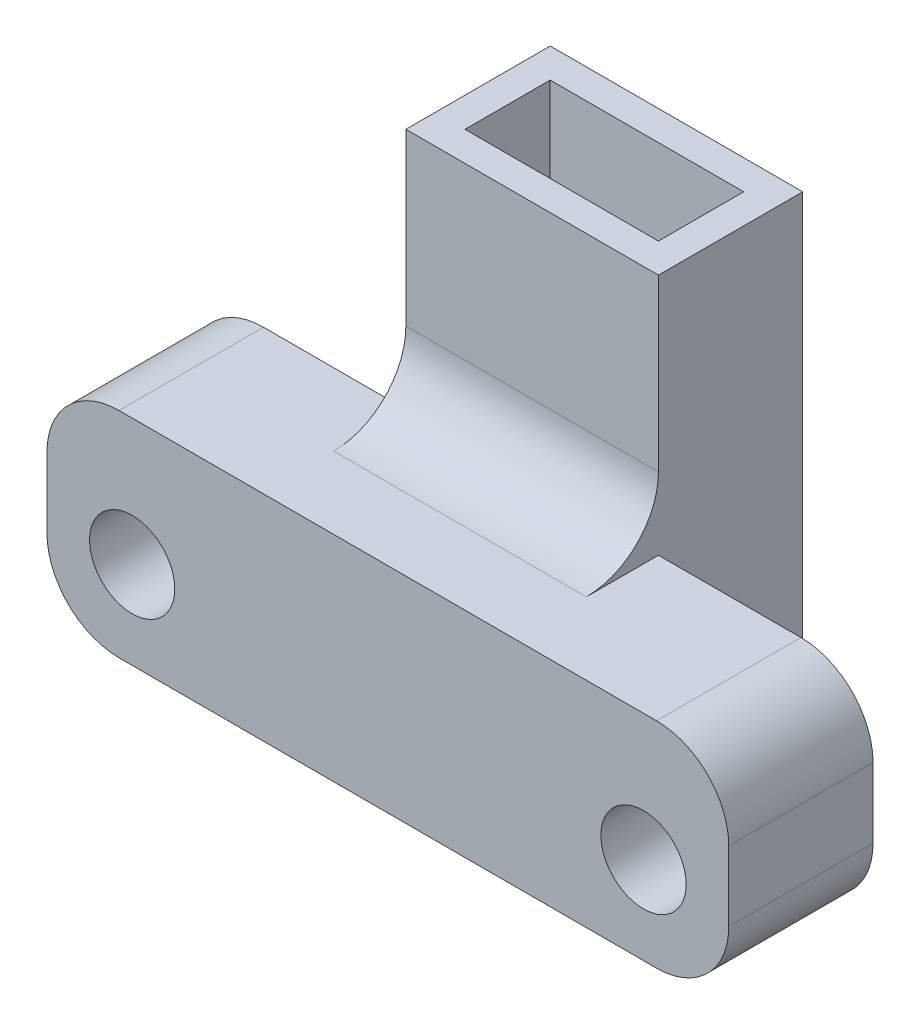
from build123d import *

# Parameters (mm, degrees)
SKETCH1_W           = 8.89
SKETCH1_H           = 5.08
BOSS_EXTRUDE1_DEPTH = 16.08
SKETCH2_W           = 24
SKETCH2_H           = 7.540516724
BOSS_EXTRUDE2_DEPTH = 5.08
SKETCH3_R           = 1.5
CUT_EXTRUDE1_DEPTH  = 11.16
SKETCH4_W           = 6.81
SKETCH4_H           = 3
CUT_EXTRUDE2_DEPTH  = 17.08
FILLET1_R           = 2.54


with BuildPart() as part:
    # Sketch1 → Boss-Extrude1 (new body)
    with BuildSketch(Plane(origin=(0, 0, 0), x_dir=(1, 0, 0), z_dir=(0, 1, 0))):
        Rectangle(SKETCH1_W, SKETCH1_H)
    extrude(amount=BOSS_EXTRUDE1_DEPTH)

    # Sketch2 → Boss-Extrude2 (add)
    with BuildSketch(Plane.XY.offset(2.54)):
        with Locations((0, 3.770258362)):
            Rectangle(SKETCH2_W, SKETCH2_H)
    extrude(amount=BOSS_EXTRUDE2_DEPTH)

    # Sketch3 → Cut-Extrude1 (cut, through all)
    with BuildSketch(Plane.XY.offset(7.62)):
        with Locations((-9, 3.07594)):
            Circle(SKETCH3_R)
        with Locations((9, 3.07594)):
            Circle(SKETCH3_R)
    extrude(amount=-CUT_EXTRUDE1_DEPTH, mode=Mode.SUBTRACT)

    # Sketch4 → Cut-Extrude2 (cut, through all)
    with BuildSketch(Plane(origin=(0, 16.08, 0), x_dir=(1, 0, 0), z_dir=(0, 1, 0))):
        Rectangle(SKETCH4_W, SKETCH4_H)
    extrude(amount=-CUT_EXTRUDE2_DEPTH, mode=Mode.SUBTRACT)

    # Fillet1
    fillet1_edges = [part.edges().sort_by_distance(p)[0] for p in [
        (12, 0, 5.08),
        (-12, 0, 5.08),
        (0, 7.540516724, 2.54),
        (12, 7.540516724, 5.08),
        (-12, 7.540516724, 5.08),
    ]]
    fillet(fillet1_edges, radius=FILLET1_R)


solid = part.part
